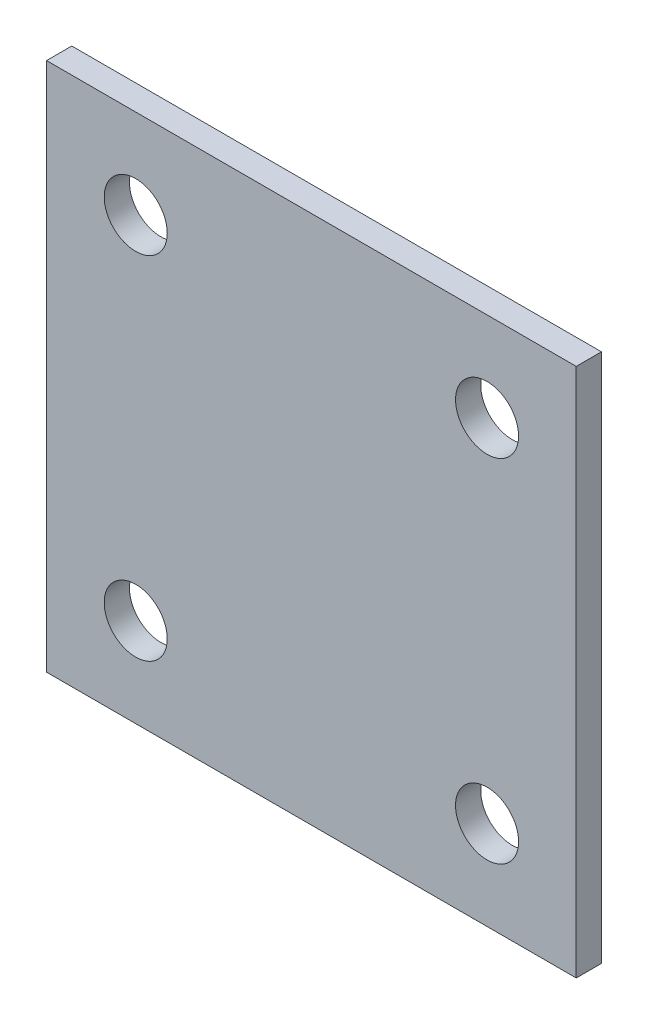
from build123d import *

# Parameters (mm, degrees)
SKETCH1_W           = 106.68
SKETCH1_H           = 106.68
SKETCH1_R           = 6.35
BOSS_EXTRUDE1_DEPTH = 5.08


with BuildPart() as part:
    # Sketch1 → Boss-Extrude1 (new body)
    with BuildSketch(Plane.XY):
        with Locations((13.609379443, -32.130150933)):
            Rectangle(SKETCH1_W, SKETCH1_H)
        with Locations((-21.770108315, 3.249336825)):
            Circle(SKETCH1_R, mode=Mode.SUBTRACT)
        with Locations((48.988867201, 3.249336825)):
            Circle(SKETCH1_R, mode=Mode.SUBTRACT)
        with Locations((-21.770108315, -67.509638691)):
            Circle(SKETCH1_R, mode=Mode.SUBTRACT)
        with Locations((48.988867201, -67.509638691)):
            Circle(SKETCH1_R, mode=Mode.SUBTRACT)
    extrude(amount=BOSS_EXTRUDE1_DEPTH)


solid = part.part
